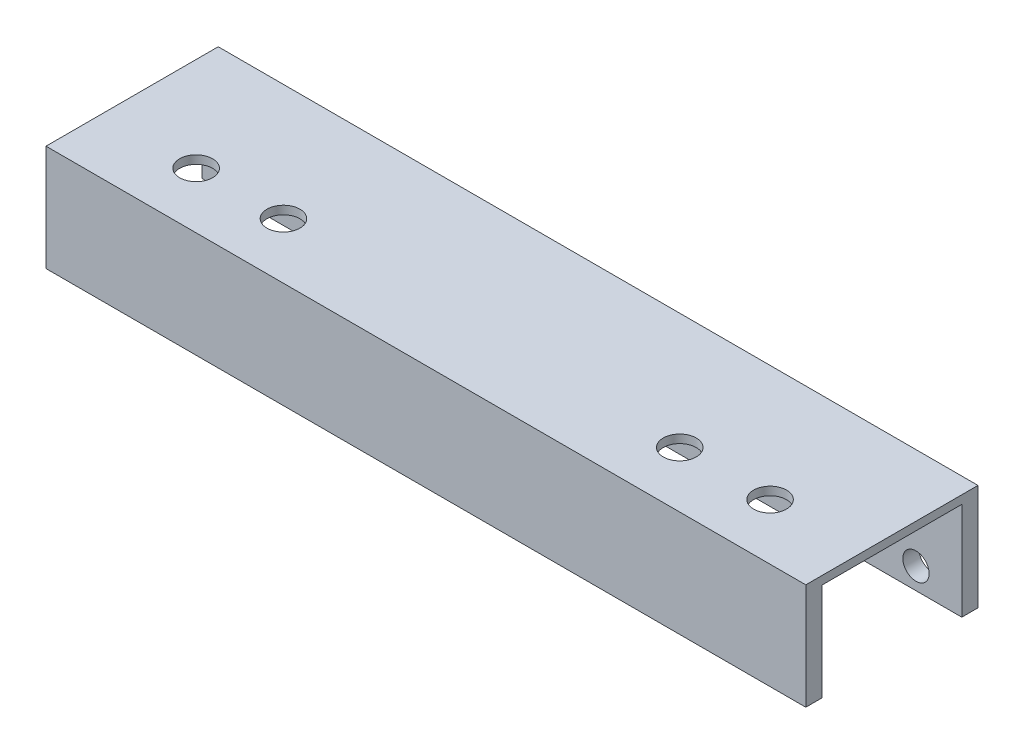
from build123d import *

# Parameters (mm, degrees)
SKETCH1_W           = 139.73
SKETCH1_H           = 31.67
BOSS_EXTRUDE1_DEPTH = 19.5
SKETCH2_W           = 139.73
SKETCH2_H           = 25.71
CUT_EXTRUDE1_DEPTH  = 17.97
HOLE1_D             = 4.84
HOLE1_DEPTH         = 2.98
HOLE2_D             = 6.06
HOLE2_DEPTH         = 1.53


with BuildPart() as part:
    # Sketch1 → Boss-Extrude1 (new body)
    with BuildSketch(Plane(origin=(0, 0, 0), x_dir=(1, 0, 0), z_dir=(0, 1, 0))):
        with Locations((69.865, -15.835)):
            Rectangle(SKETCH1_W, SKETCH1_H)
    extrude(amount=BOSS_EXTRUDE1_DEPTH)

    # Sketch2 → Cut-Extrude1 (cut)
    with BuildSketch(Plane.XZ):
        with Locations((69.865, 15.835)):
            Rectangle(SKETCH2_W, SKETCH2_H)
    extrude(amount=-CUT_EXTRUDE1_DEPTH, mode=Mode.SUBTRACT)

    # Hole1
    with Locations(Plane(origin=(0, 0, 0), x_dir=(-1, 0, 0), z_dir=(0, 0, -1))):
        with Locations((-131.3, 3.93), (-96.59, 3.93), (-43.14, 3.93), (-8.43, 3.93)):
            Hole(HOLE1_D / 2, depth=HOLE1_DEPTH)

    # Hole2
    with Locations(Plane(origin=(0, 19.5, 0), x_dir=(-1, 0, 0), z_dir=(0, 1, 0))):
        with Locations((-122.87, 21.38), (-106.26, 21.38), (-33.38, 21.38), (-17.32, 21.38)):
            Hole(HOLE2_D / 2, depth=HOLE2_DEPTH)


solid = part.part
